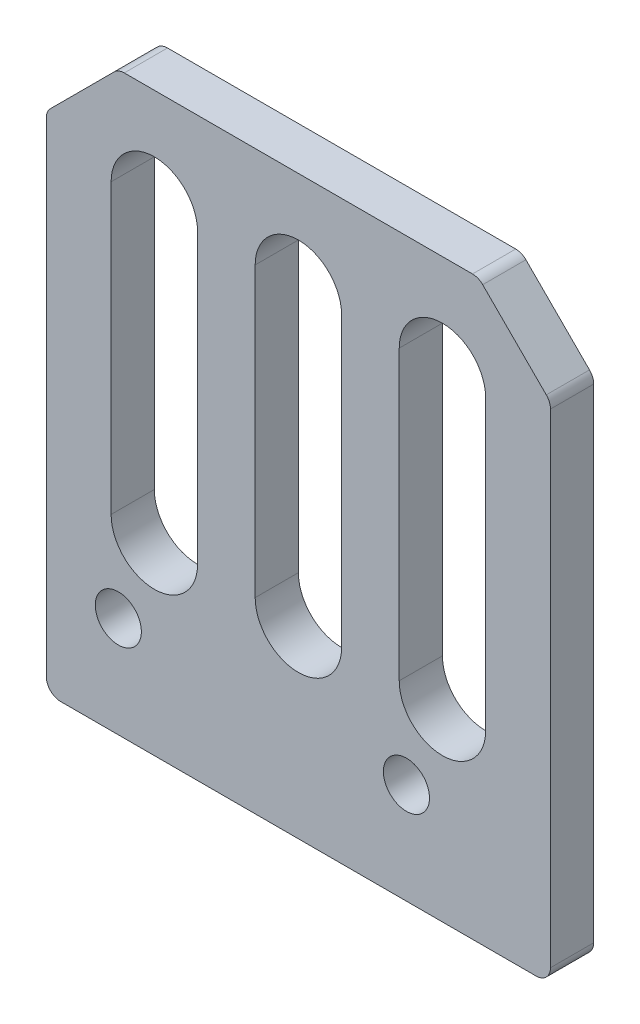
from build123d import *

# Parameters (mm, degrees)
SKETCH_1_W          = 35
SKETCH_1_H          = 40
EXTRUDE_1_DEPTH     = 3
CHAMFER_1_SIZE      = 5
FILLET_1_R          = 1
SKETCH_2_R          = 1.6
CUT_EXTRUDE_1_DEPTH = 4
CUT_EXTRUDE_2_DEPTH = 4


with BuildPart() as part:
    # 草图1 → 凸台-拉伸1 (new body)
    with BuildSketch(Plane.XY):
        Rectangle(SKETCH_1_W, SKETCH_1_H)
    extrude(amount=EXTRUDE_1_DEPTH)

    # 倒角1
    chamfer_1_edges = [part.edges().sort_by_distance(p)[0] for p in [
        (-17.5, 20, 1.5),
        (17.5, 20, 1.5),
    ]]
    chamfer(chamfer_1_edges, length=CHAMFER_1_SIZE)

    # 圆角1
    fillet_1_edges = [part.edges().sort_by_distance(p)[0] for p in [
        (-17.5, 15, 1.5),
        (12.5, 20, 1.5),
        (-12.5, 20, 1.5),
        (17.5, 15, 1.5),
        (17.5, -20, 1.5),
        (-17.5, -20, 1.5),
    ]]
    fillet(fillet_1_edges, radius=FILLET_1_R)

    # 草图2 → 切除-拉伸1 (cut, through all)
    with BuildSketch(Plane.XY.offset(3)):
        with Locations((-12.5, -13)):
            Circle(SKETCH_2_R)
        with Locations((7.5, -13)):
            Circle(SKETCH_2_R)
    extrude(amount=-CUT_EXTRUDE_1_DEPTH, mode=Mode.SUBTRACT)

    # 草图3 → 切除-拉伸2 (cut, through all)
    with BuildSketch(Plane.XY.offset(3)):
        with BuildLine():
            Line((3, 13), (3, -7))
            ThreePointArc((3, -7), (0, -10), (-3, -7))
            Line((-3, -7), (-3, 13))
            ThreePointArc((-3, 13), (0, 16), (3, 13))
        make_face()
        with BuildLine():
            Line((-7, 13), (-7, -7))
            ThreePointArc((-7, -7), (-10, -10), (-13, -7))
            Line((-13, -7), (-13, 13))
            ThreePointArc((-13, 13), (-10, 16), (-7, 13))
        make_face()
        with BuildLine():
            Line((13, 13), (13, -7))
            ThreePointArc((13, -7), (10, -10), (7, -7))
            Line((7, -7), (7, 13))
            ThreePointArc((7, 13), (10, 16), (13, 13))
        make_face()
    extrude(amount=-CUT_EXTRUDE_2_DEPTH, mode=Mode.SUBTRACT)


solid = part.part
